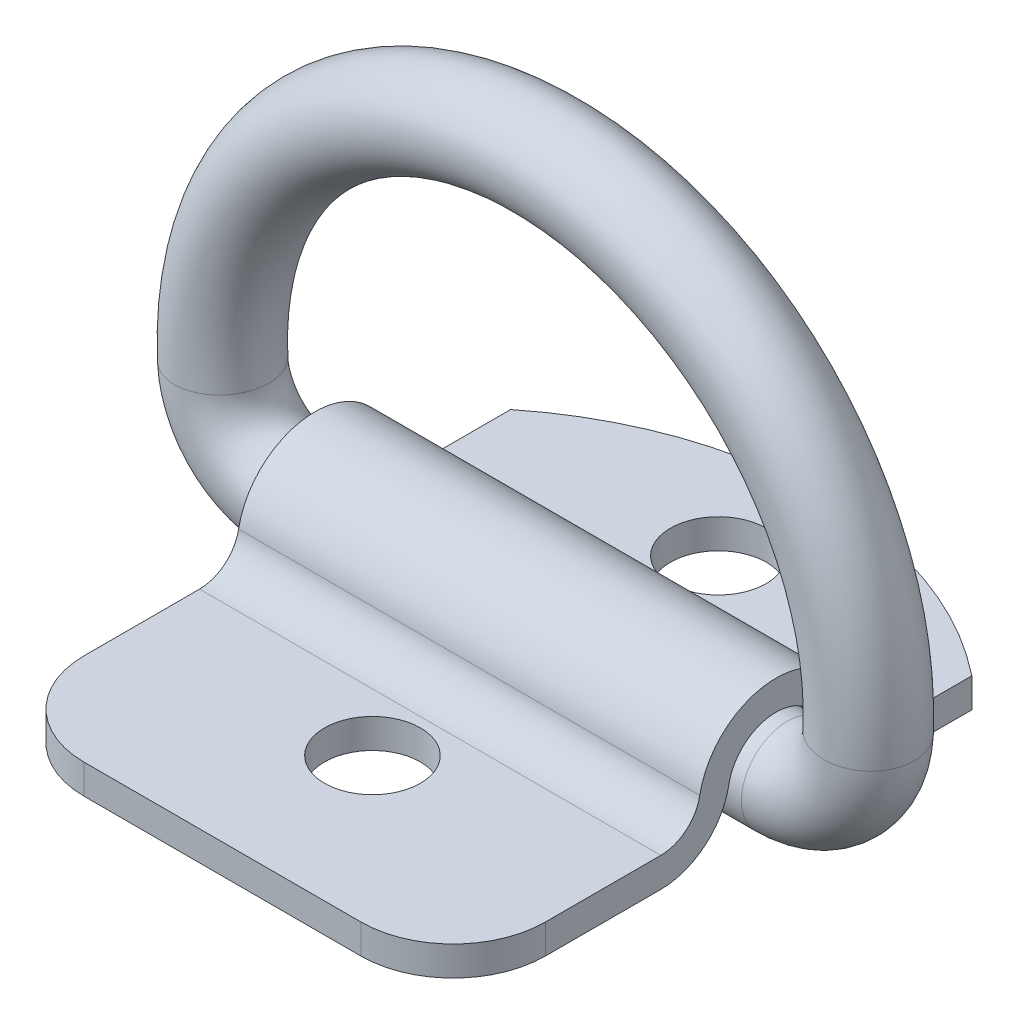
from build123d import *

# Parameters (mm, degrees)
SKETCH2_R           = 3.175
BOSS_EXTRUDE1_DEPTH = 15.875
SKETCH4_R           = 3.302
CUT_EXTRUDE1_DEPTH  = 36.0520001


with BuildPart() as part:
    # Sweep1: sweep along a path in Sketch1
    with BuildLine(Plane.XY) as sweep1_path:
        Line((-16.66875, 0), (16.66875, 0))
        ThreePointArc((16.66875, 0), (20.505205868, 1.537105758), (22.218993243, 5.297959459))
        ThreePointArc((22.218993243, 5.297959459), (0, 28.575), (-22.218993243, 5.297959459))
        ThreePointArc((-22.218993243, 5.297959459), (-20.505205868, 1.537105758), (-16.66875, 0))
    # Sketch2 → Sweep1 (sweep)
    with BuildSketch(Plane(origin=(0, 0, 0), x_dir=(0, 0, -1), z_dir=(1, 0, 0))):
        Circle(SKETCH2_R)
    sweep(path=sweep1_path.line)


with BuildPart() as body_2:
    # Sketch3 → Boss-Extrude1 (new body, symmetric)
    with BuildSketch(Plane(origin=(0, 0, 0), x_dir=(0, 0, -1), z_dir=(1, 0, 0))):
        with BuildLine():
            Line((-22.225, -3.302), (-22.225, -1.27))
            Line((-22.225, -1.27), (-7.931147458, -1.27))
            ThreePointArc((-7.931147458, -1.27), (-6.183949988, -0.637816289), (-5.245798319, 0.966))
            ThreePointArc((-5.245798319, 0.966), (0, 5.334), (5.245798319, 0.966))
            ThreePointArc((5.245798319, 0.966), (6.183949988, -0.637816289), (7.931147458, -1.27))
            Line((7.931147458, -1.27), (19.05, -1.27))
            Line((19.05, -1.27), (19.05, -3.302))
            Line((19.05, -3.302), (7.931147458, -3.302))
            ThreePointArc((7.931147458, -3.302), (4.88371001, -2.199353993), (3.247398959, 0.598))
            ThreePointArc((3.247398959, 0.598), (0, 3.302), (-3.247398959, 0.598))
            ThreePointArc((-3.247398959, 0.598), (-4.88371001, -2.199353993), (-7.931147458, -3.302))
            Line((-7.931147458, -3.302), (-22.225, -3.302))
        make_face()
    extrude(amount=BOSS_EXTRUDE1_DEPTH, both=True)

    # Sketch4 → Cut-Extrude1 (cut, through all)
    with BuildSketch(Plane.XZ.offset(3.302)):
        with Locations((0, 11.90625)):
            Circle(SKETCH4_R)
        with Locations((0, -11.90625)):
            Circle(SKETCH4_R)
        with BuildLine():
            Line((-15.875, 15.875), (-15.875, 22.225))
            Line((-15.875, 22.225), (-9.525, 22.225))
            ThreePointArc((-9.525, 22.225), (-14.015128061, 20.365128061), (-15.875, 15.875))
        make_face()
        with BuildLine():
            Line((15.875, 22.225), (9.525, 22.225))
            ThreePointArc((9.525, 22.225), (14.015128061, 20.365128061), (15.875, 15.875))
            Line((15.875, 15.875), (15.875, 22.225))
        make_face()
        with BuildLine():
            Line((15.875, -19.05), (15.875, -13.477868645))
            ThreePointArc((15.875, -13.477868645), (0, -19.05), (-15.875, -13.477868645))
            Line((-15.875, -13.477868645), (-15.875, -19.05))
            Line((-15.875, -19.05), (-15.875, -20.32))
            Line((-15.875, -20.32), (15.875, -20.32))
            Line((15.875, -20.32), (15.875, -19.05))
        make_face()
    extrude(amount=-CUT_EXTRUDE1_DEPTH, mode=Mode.SUBTRACT)


solid = Compound([part.part, body_2.part])
